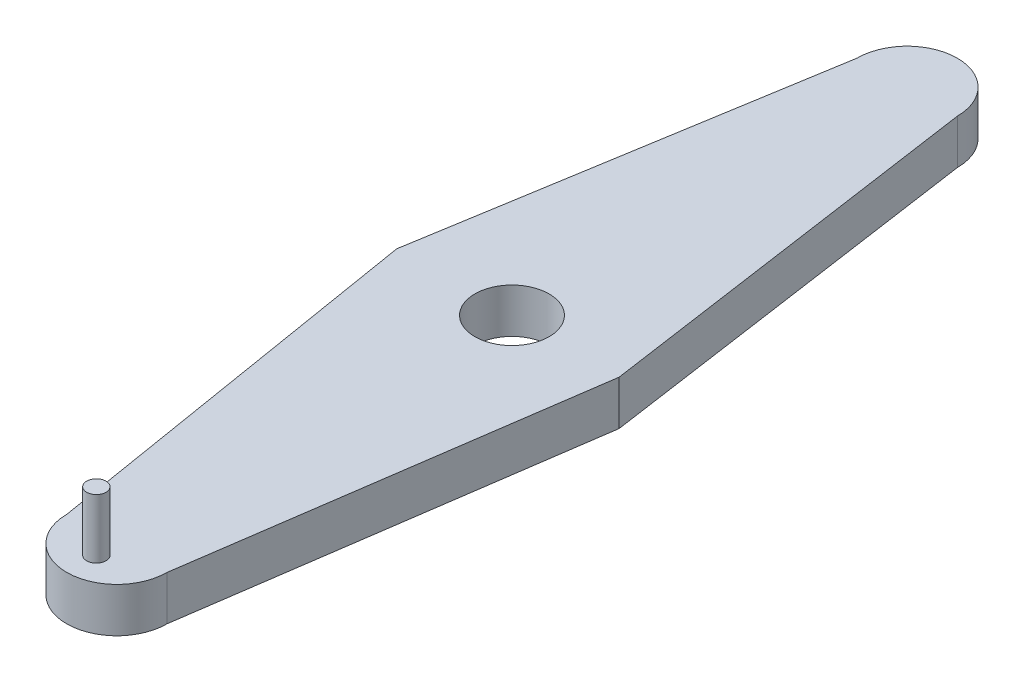
from build123d import *

# Parameters (mm, degrees)
BOSS_EXTRUDE1_DEPTH = 30
SKETCH2_R           = 25
CUT_EXTRUDE1_DEPTH  = 30
SKETCH3_R           = 6.505
BOSS_EXTRUDE2_DEPTH = 40


with BuildPart() as part:
    # Sketch1 → Boss-Extrude1 (new body)
    with BuildSketch(Plane(origin=(0, 0, 0), x_dir=(1, 0, 0), z_dir=(0, 1, 0))):
        with BuildLine():
            Line((-77.61802258, 0), (-33.820586084, 266.179413916))
            ThreePointArc((-33.820586084, 266.179413916), (0, 300), (33.820586084, 266.179413916))
            Line((33.820586084, 266.179413916), (72.176610565, 0))
            Line((72.176610565, 0), (33.820586084, -266.179413916))
            ThreePointArc((33.820586084, -266.179413916), (0, -300), (-33.820586084, -266.179413916))
            Line((-33.820586084, -266.179413916), (-77.61802258, 0))
        make_face()
    extrude(amount=BOSS_EXTRUDE1_DEPTH)

    # Sketch2 → Cut-Extrude1 (cut)
    with BuildSketch(Plane(origin=(0, 30, 0), x_dir=(1, 0, 0), z_dir=(0, 1, 0))):
        Circle(SKETCH2_R)
    extrude(amount=-CUT_EXTRUDE1_DEPTH, mode=Mode.SUBTRACT)

    # Sketch3 → Boss-Extrude2 (add)
    with BuildSketch(Plane(origin=(0, 30, 0), x_dir=(1, 0, 0), z_dir=(0, 1, 0))):
        with Locations((0, -280)):
            Circle(SKETCH3_R)
    extrude(amount=BOSS_EXTRUDE2_DEPTH)


solid = part.part
